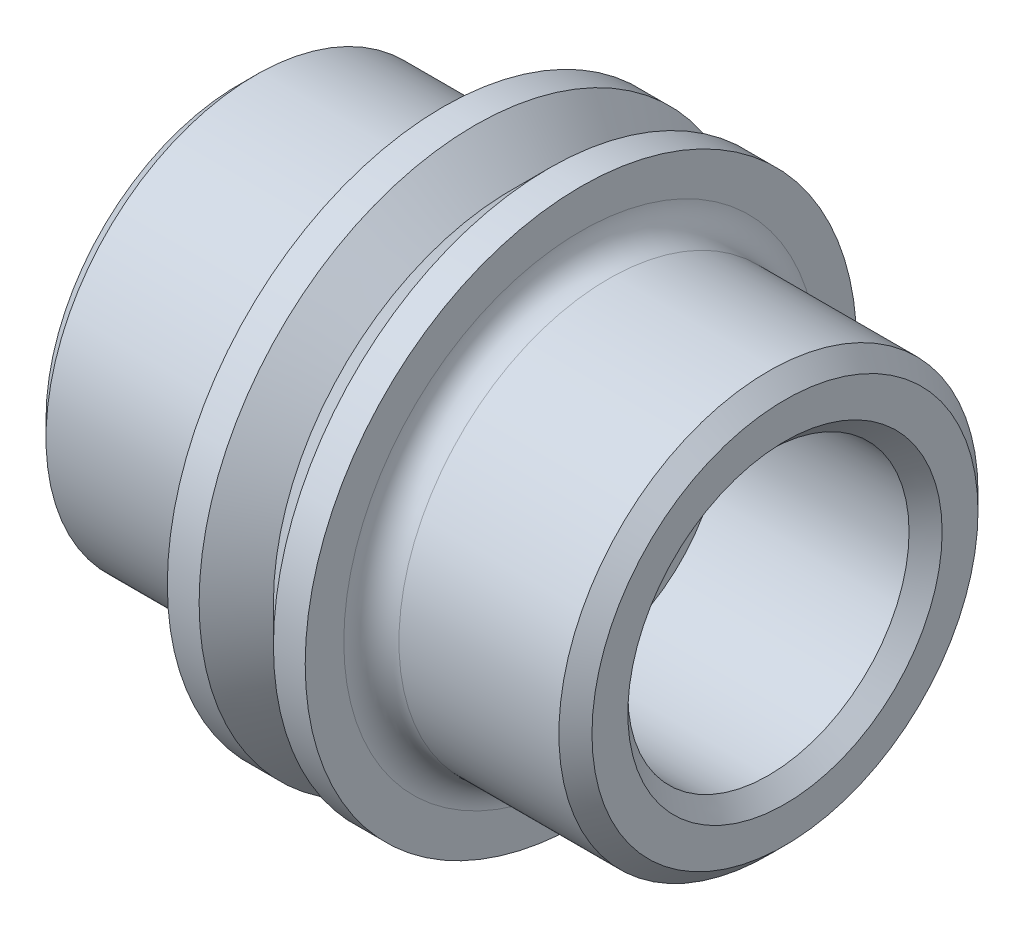
from build123d import *

# Parameters (mm, degrees)
SKETCH1_R           = 6.35
BOSS_EXTRUDE1_DEPTH = 1.5875
SKETCH2_R           = 4.826
SKETCH2_R_2         = 3.2385
BOSS_EXTRUDE2_DEPTH = 6.2865
CHAMFER1_SIZE       = 0.381
FILLET2_R           = 0.635


with BuildPart() as part:
    # Sketch1 → Boss-Extrude1 (new body, symmetric)
    with BuildSketch(Plane(origin=(0, 0, 0), x_dir=(0, 0, -1), z_dir=(1, 0, 0))):
        Circle(SKETCH1_R)
    extrude(amount=BOSS_EXTRUDE1_DEPTH, both=True)

    # Sketch2 → Boss-Extrude2 (add, symmetric)
    with BuildSketch(Plane(origin=(0, 0, 0), x_dir=(0, 0, -1), z_dir=(1, 0, 0))):
        Circle(SKETCH2_R)
        Circle(SKETCH2_R_2, mode=Mode.SUBTRACT)
    extrude(amount=BOSS_EXTRUDE2_DEPTH, both=True)

    # Chamfer1
    chamfer1_edges = [part.edges().sort_by_distance(p)[0] for p in [
        (-6.2865, 0, 4.826),
        (6.2865, 0, 4.826),
        (-6.2865, 0, 3.2385),
        (6.2865, 0, 3.2385),
    ]]
    chamfer(chamfer1_edges, length=CHAMFER1_SIZE)

    # Fillet2
    fillet2_edges = [part.edges().sort_by_distance(p)[0] for p in [
        (-1.5875, 0, 4.826),
        (1.5875, 0, 4.826),
    ]]
    fillet(fillet2_edges, radius=FILLET2_R)

    # Cut-Sweep1: sweep along a path in Sketch3
    with BuildLine(Plane(origin=(0, 0, 0), x_dir=(0, 0, -1), z_dir=(1, 0, 0))) as cut_sweep1_path:
        CenterArc((0, 0), 6.35, 0, 360)
    # Sketch7 → Cut-Sweep1 (sweep, cut)
    with BuildSketch(Plane(origin=(0, 0, 0), x_dir=(1, 0, 0), z_dir=(0, 1, 0))):
        Polygon((1.27, -6.764445418), (-1.27, -6.764445418), (0, -5.494445418), align=None)
    sweep(path=cut_sweep1_path.line, mode=Mode.SUBTRACT)


solid = part.part
